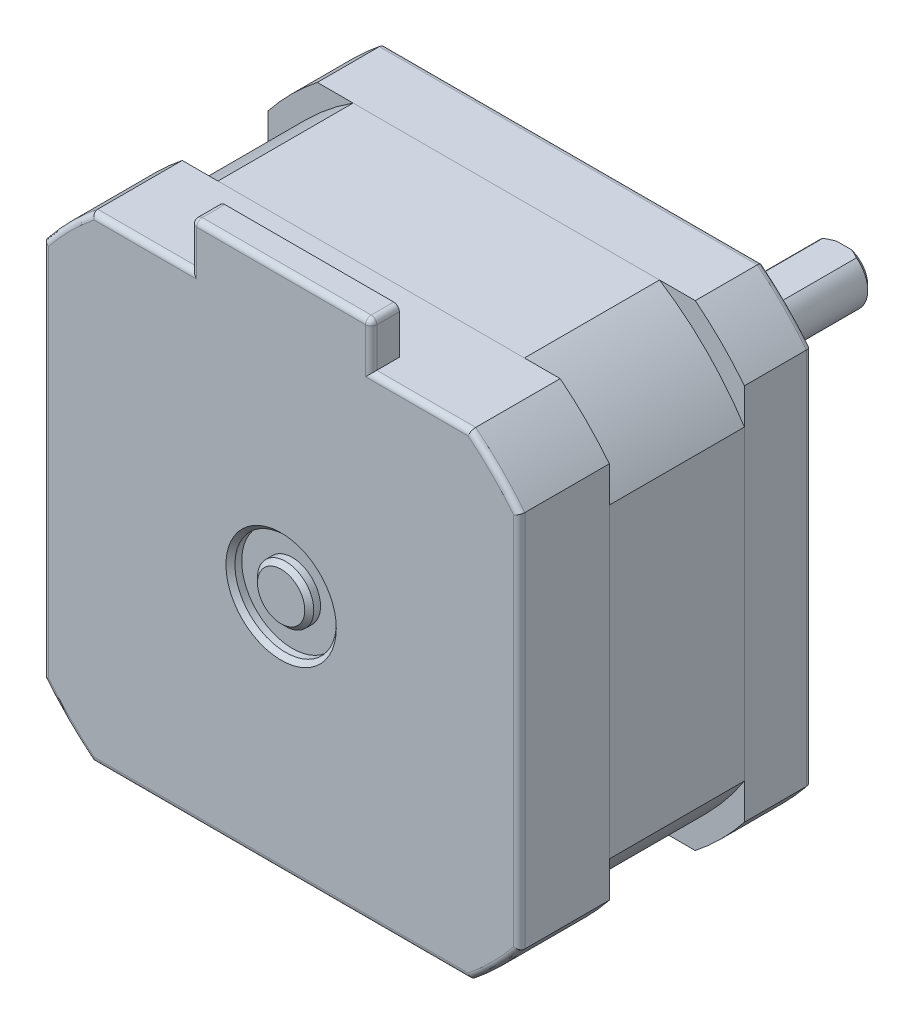
from build123d import *

# Parameters (mm, degrees)
BOSS_EXTRU_1_DEPTH           = 6
BOSS_EXTRU_2_DEPTH           = 12
BOSS_EXTRU_3_DEPTH           = 8
ESQUISSE4_W                  = 16
ESQUISSE4_H                  = 2.5
BOSS_EXTRU_4_DEPTH           = 4
ESQUISSE5_W                  = 2
ESQUISSE5_H                  = 6.5
ESQUISSE5_W_2                = 24
ESQUISSE5_H_2                = 2.5
CONG_1_R                     = 0.5
CONG_2_R                     = 0.5
CHANFREIN1_SIZE              = 0.4
CHANFREIN2_SIZE              = 0.4
ESQUISSE6_W                  = 15
ESQUISSE6_H                  = 0.5
ENL_V_MAT_EXTRU_1_DEPTH      = 22.1500001
ENL_V_MAT_EXTRU_1_DEPTH_BACK = 22.1500001
ESQUISSE7_R                  = 4.5
ESQUISSE7_R_2                = 2.5
ENL_V_MAT_EXTRU_2_DEPTH      = 1
CHANFREIN3_SIZE              = 0.4
TROU_TARAUD_M31_AT_2_COUNT   = 2
TROU_TARAUD_M31_AT_2_PITCH   = 31
TROU_TARAUD_M31_AT_3_COUNT   = 2
TROU_TARAUD_M31_AT_3_PITCH   = 43.840620434
TROU_TARAUD_M31_AT_4_COUNT   = 2
TROU_TARAUD_M31_AT_4_PITCH   = 31


with BuildPart() as part:
    # Esquisse1 → Boss.-Extru.1 (new body)
    with BuildSketch(Plane.XY):
        with BuildLine():
            Line((21.15, 16.783250579), (21.15, -16.783250579))
            ThreePointArc((21.15, -16.783250579), (19.091883092, -19.091883092), (16.783250579, -21.15))
            Line((16.783250579, -21.15), (-16.783250579, -21.15))
            ThreePointArc((-16.783250579, -21.15), (-19.091883092, -19.091883092), (-21.15, -16.783250579))
            Line((-21.15, -16.783250579), (-21.15, 16.783250579))
            ThreePointArc((-21.15, 16.783250579), (-19.091883092, 19.091883092), (-16.783250579, 21.15))
            Line((-16.783250579, 21.15), (16.783250579, 21.15))
            ThreePointArc((16.783250579, 21.15), (19.091883092, 19.091883092), (21.15, 16.783250579))
        make_face()
    extrude(amount=BOSS_EXTRU_1_DEPTH)

    # Congé2
    cong_2_edges = [part.edges().sort_by_distance(p)[0] for p in [
        (0, 21.15, 0),
        (19.091883092, 19.091883092, 0),
        (21.15, 0, 0),
        (19.091883092, -19.091883092, 0),
        (0, -21.15, 0),
        (-19.091883092, -19.091883092, 0),
        (-21.15, 0, 0),
        (-19.091883092, 19.091883092, 0),
    ]]
    fillet(cong_2_edges, radius=CONG_2_R)

    # Esquisse9 → Trou taraudé M31 (revolve, cut)
    with BuildSketch(Plane(origin=(15.5, -15.5, 0), x_dir=(0, 1, 0), z_dir=(1, 0, 0))):
        Polygon((0, 0), (0, 5.751075774), (1.25, 5), (1.25, 0), align=None)
    trou_taraud_m31 = revolve(axis=Axis((15.5, -15.5, -6.35), (0, 0, 1)), mode=Mode.SUBTRACT)

    # Trou taraudé M31 at 2: Trou taraudé M31 ×2
    with Locations(*[(0, i * TROU_TARAUD_M31_AT_2_PITCH, 0) for i in range(1, TROU_TARAUD_M31_AT_2_COUNT)]):
        add(trou_taraud_m31, mode=Mode.SUBTRACT)

    # Trou taraudé M31 at 3: Trou taraudé M31 ×2
    with Locations(*[Vector(-0.707106781, 0.707106781, 0) * (i * TROU_TARAUD_M31_AT_3_PITCH) for i in range(1, TROU_TARAUD_M31_AT_3_COUNT)]):
        add(trou_taraud_m31, mode=Mode.SUBTRACT)

    # Trou taraudé M31 at 4: Trou taraudé M31 ×2
    with Locations(*[(-i * TROU_TARAUD_M31_AT_4_PITCH, 0, 0) for i in range(1, TROU_TARAUD_M31_AT_4_COUNT)]):
        add(trou_taraud_m31, mode=Mode.SUBTRACT)


with BuildPart() as body_2:
    # Esquisse2 → Boss.-Extru.2 (new body)
    with BuildSketch(Plane.XY.offset(6)):
        with BuildLine():
            Line((-13.608820669, 21.15), (13.608820669, 21.15))
            ThreePointArc((13.608820669, 21.15), (17.783735547, 17.783735547), (21.15, 13.608820669))
            Line((21.15, 13.608820669), (21.15, -13.608820669))
            ThreePointArc((21.15, -13.608820669), (17.783735547, -17.783735547), (13.608820669, -21.15))
            Line((13.608820669, -21.15), (-13.608820669, -21.15))
            ThreePointArc((-13.608820669, -21.15), (-17.783735547, -17.783735547), (-21.15, -13.608820669))
            Line((-21.15, -13.608820669), (-21.15, 13.608820669))
            ThreePointArc((-21.15, 13.608820669), (-17.783735547, 17.783735547), (-13.608820669, 21.15))
        make_face()
    extrude(amount=BOSS_EXTRU_2_DEPTH)


with BuildPart() as body_3:
    # Esquisse3 → Boss.-Extru.3 (new body)
    with BuildSketch(Plane.XY.offset(18)):
        with BuildLine():
            Line((-16.783250579, -21.15), (16.783250579, -21.15))
            ThreePointArc((16.783250579, -21.15), (19.091883092, -19.091883092), (21.15, -16.783250579))
            Line((21.15, -16.783250579), (21.15, 16.783250579))
            ThreePointArc((21.15, 16.783250579), (19.091883092, 19.091883092), (16.783250579, 21.15))
            Line((16.783250579, 21.15), (-16.783250579, 21.15))
            ThreePointArc((-16.783250579, 21.15), (-19.091883092, 19.091883092), (-21.15, 16.783250579))
            Line((-21.15, 16.783250579), (-21.15, -16.783250579))
            ThreePointArc((-21.15, -16.783250579), (-19.091883092, -19.091883092), (-16.783250579, -21.15))
        make_face()
    extrude(amount=BOSS_EXTRU_3_DEPTH)

    # Esquisse4 → Boss.-Extru.4 (add)
    with BuildSketch(Plane(origin=(0, 21.15, 0), x_dir=(1, 0, 0), z_dir=(0, 1, 0))):
        with Locations((0, -24.75)):
            Rectangle(ESQUISSE4_W, ESQUISSE4_H)
    extrude(amount=BOSS_EXTRU_4_DEPTH)

    # Congé1
    cong_1_edges = [body_3.edges().sort_by_distance(p)[0] for p in [
        (19.091883092, -19.091883092, 26),
        (21.15, 0, 26),
        (19.091883092, 19.091883092, 26),
        (12.39162529, 21.15, 26),
        (-19.091883092, 19.091883092, 26),
        (-21.15, 0, 26),
        (-12.39162529, 21.15, 26),
        (8, 23.15, 26),
        (-8, 23.15, 26),
        (8, 25.15, 24.75),
        (-8, 25.15, 24.75),
        (0, 25.15, 26),
        (-19.091883092, -19.091883092, 26),
        (0, -21.15, 26),
    ]]
    fillet(cong_1_edges, radius=CONG_1_R)

    # Esquisse7 → Enlèv. mat.-Extru.2 (cut)
    with BuildSketch(Plane.XY.offset(26)):
        Circle(ESQUISSE7_R)
        Circle(ESQUISSE7_R_2, mode=Mode.SUBTRACT)
    extrude(amount=-ENL_V_MAT_EXTRU_2_DEPTH, mode=Mode.SUBTRACT)

    # Chanfrein3
    chanfrein3_edges = [body_3.edges().sort_by_distance(p)[0] for p in [
        (-4.5, 0, 26),
        (-2.5, 0, 26),
    ]]
    chamfer(chanfrein3_edges, length=CHANFREIN3_SIZE)


with BuildPart() as body_4:
    # Esquisse5 → Révolution1 (revolve)
    with BuildSketch(Plane(origin=(0, 0, 0), x_dir=(0, 0, -1), z_dir=(1, 0, 0))):
        with Locations((1, 7.75)):
            Rectangle(ESQUISSE5_W, ESQUISSE5_H)
        with Locations((12, 1.25)):
            Rectangle(ESQUISSE5_W_2, ESQUISSE5_H_2)
    revolve(axis=Axis((0, 0, 0), (0, 0, 1)))

    # Chanfrein1
    chanfrein1_edges = [body_4.edges().sort_by_distance(p)[0] for p in [
        (0, -2.5, -24),
    ]]
    chamfer(chanfrein1_edges, length=CHANFREIN1_SIZE)

    # Chanfrein2
    chanfrein2_edges = [body_4.edges().sort_by_distance(p)[0] for p in [
        (0, -11, -2),
        (0, -4.5, -2),
    ]]
    chamfer(chanfrein2_edges, length=CHANFREIN2_SIZE)

    # Esquisse6 → Enlèv. mat.-Extru.1 (cut, two sides)
    with BuildSketch(Plane(origin=(0, 0, 0), x_dir=(0, 0, -1), z_dir=(1, 0, 0))) as enl_v_mat_extru_1_sk:
        with Locations((16.5, 2.25)):
            Rectangle(ESQUISSE6_W, ESQUISSE6_H)
    extrude(amount=ENL_V_MAT_EXTRU_1_DEPTH, mode=Mode.SUBTRACT)
    extrude(enl_v_mat_extru_1_sk.sketch, amount=-ENL_V_MAT_EXTRU_1_DEPTH_BACK, mode=Mode.SUBTRACT)


solid = Compound([part.part, body_2.part, body_3.part, body_4.part])
